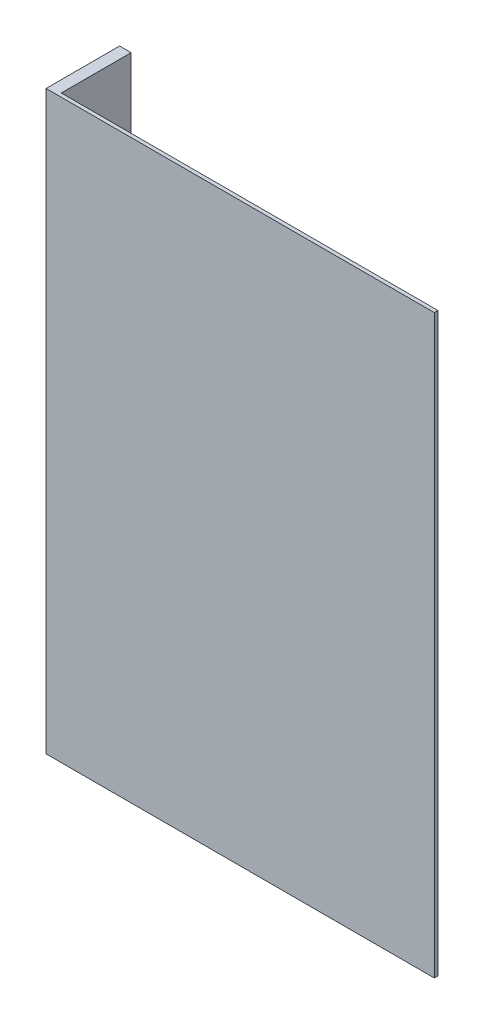
from build123d import *

# Parameters (mm, degrees)
BOSS_EXTRUDE1_DEPTH = 0.8
BOSS_EXTRUDE2_DEPTH = 0.8
BOSS_EXTRUDE3_DEPTH = 15.4


with BuildPart() as part:
    # Sketch1 → Boss-Extrude1 (new body)
    with BuildSketch(Plane.XY):
        Polygon((2.591679003, 2.54), (2.591679003, -124.46), (-72.414230485, -124.46), (-72.414230485, -121.92), (-72.414230485, 2.54), align=None)
    extrude(amount=BOSS_EXTRUDE1_DEPTH)

    # Sketch2 → Boss-Extrude2 (add)
    with BuildSketch(Plane.XY):
        Polygon((-72.414230485, -124.46), (-80.414230485, -124.46), (-82.954230485, -124.46), (-82.954230485, -112.46), (-82.954230485, 2.54), (-72.414230485, 2.54), (-72.414230485, -9.46), (-72.414230485, -112.46), align=None)
    extrude(amount=BOSS_EXTRUDE2_DEPTH)

    # Sketch3 → Boss-Extrude3 (add)
    with BuildSketch(Plane(origin=(0, 0, 0), x_dir=(-1, 0, 0), z_dir=(0, 0, -1))):
        Polygon((82.954230485, 2.54), (80.414230485, 2.54), (80.414230485, -9.46), (80.414230485, -112.46), (80.414230485, -124.46), (82.954230485, -124.46), (82.954230485, -112.46), (82.954230485, -9.46), align=None)
    extrude(amount=BOSS_EXTRUDE3_DEPTH)


solid = part.part
